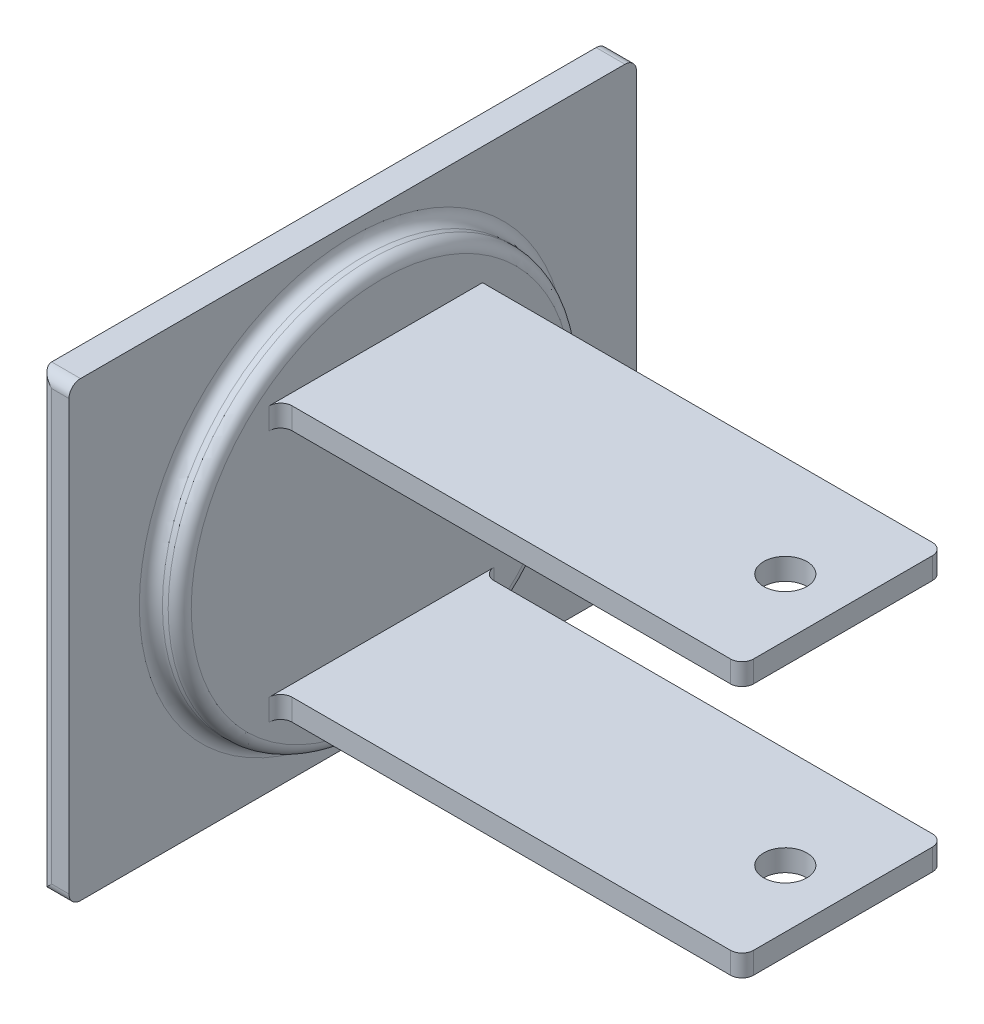
from build123d import *

# Parameters (mm, degrees)
SKETCH1_W           = 124.968
SKETCH1_H           = 99.568
BOSS_EXTRUDE1_DEPTH = 6.35
SKETCH2_R           = 44.45
BOSS_EXTRUDE2_DEPTH = 6.35
SKETCH3_W           = 44.45
SKETCH3_H           = 4.7625
BOSS_EXTRUDE3_DEPTH = 101.6
SKETCH4_R           = 4.7625
CUT_EXTRUDE1_DEPTH  = 80.9465
FILLET1_R           = 2.54


with BuildPart() as part:
    # Sketch1 → Boss-Extrude1 (new body)
    with BuildSketch(Plane(origin=(0, 0, 0), x_dir=(0, 0, -1), z_dir=(1, 0, 0))):
        with Locations((62.484, 49.784)):
            Rectangle(SKETCH1_W, SKETCH1_H)
    extrude(amount=BOSS_EXTRUDE1_DEPTH)

    # Sketch2 → Boss-Extrude2 (add)
    with BuildSketch(Plane(origin=(6.35, 0, 0), x_dir=(0, 0, -1), z_dir=(1, 0, 0))):
        with Locations((62.484, 49.784)):
            Circle(SKETCH2_R)
    extrude(amount=BOSS_EXTRUDE2_DEPTH)

    # Sketch3 → Boss-Extrude3 (add)
    with BuildSketch(Plane(origin=(12.7, 0, 0), x_dir=(0, 0, -1), z_dir=(1, 0, 0))):
        with Locations((62.484, 77.56525)):
            Rectangle(SKETCH3_W, SKETCH3_H)
        with Locations((62.484, 22.00275)):
            Rectangle(SKETCH3_W, SKETCH3_H)
    extrude(amount=BOSS_EXTRUDE3_DEPTH)

    # Sketch4 → Cut-Extrude1 (cut, through all)
    with BuildSketch(Plane.XZ.offset(-19.6215)):
        with Locations((101.6, -62.484)):
            Circle(SKETCH4_R)
    extrude(amount=-CUT_EXTRUDE1_DEPTH, mode=Mode.SUBTRACT)

    # Fillet1
    fillet1_edges = [part.edges().sort_by_distance(p)[0] for p in [
        (6.35, 49.784, -18.034),
        (12.7, 49.784, -18.034),
        (12.7, 77.56525, -40.259),
        (114.3, 77.56525, -84.709),
        (114.3, 77.56525, -40.259),
        (12.7, 22.00275, -84.709),
        (12.7, 22.00275, -40.259),
        (114.3, 22.00275, -84.709),
        (114.3, 22.00275, -40.259),
        (0, 49.784, 0),
        (3.175, 99.568, 0),
        (3.175, 99.568, -124.968),
        (3.175, 0, -124.968),
        (3.175, 0, 0),
    ]]
    fillet(fillet1_edges, radius=FILLET1_R)


solid = part.part
